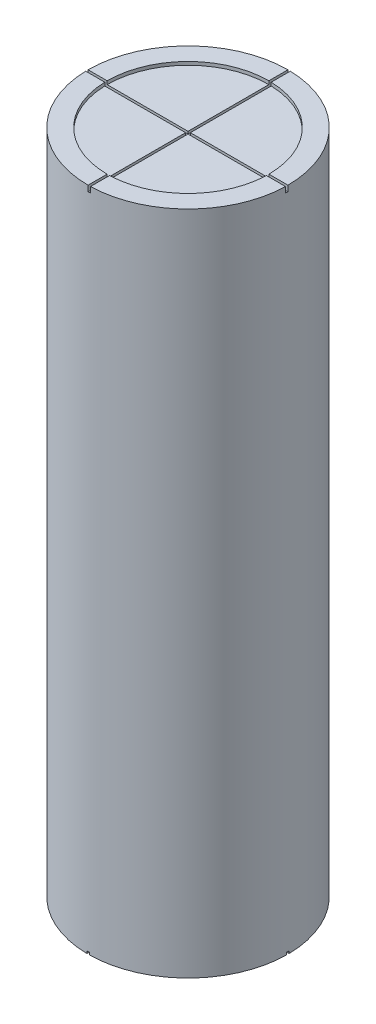
from build123d import *

# Parameters (mm, degrees)
SKETCH1_R               = 10.5
BOSS_EXTRUDE1_DEPTH     = 70
SKETCH2_R               = 8.5
CUT_EXTRUDE1_DEPTH      = 0.35
SKETCH3_W               = 21
SKETCH3_H               = 0.25
SKETCH3_W_2             = 0.25
SKETCH3_H_2             = 21
CUT_EXTRUDE_THIN1_DEPTH = 0.25
CUT_EXTRUDE_THIN2_START = 70
SKETCH3_2_W             = 21
SKETCH3_2_H             = 0.25
SKETCH3_2_W_2           = 0.25
SKETCH3_2_H_2           = 21
CUT_EXTRUDE_THIN2_DEPTH = 0.6


with BuildPart() as part:
    # Sketch1 → Boss-Extrude1 (new body)
    with BuildSketch(Plane(origin=(0, 0, 0), x_dir=(1, 0, 0), z_dir=(0, 1, 0))):
        Circle(SKETCH1_R)
    extrude(amount=BOSS_EXTRUDE1_DEPTH)

    # Sketch2 → Cut-Extrude1 (cut)
    with BuildSketch(Plane(origin=(0, 70, 0), x_dir=(1, 0, 0), z_dir=(0, 1, 0))):
        Circle(SKETCH2_R)
    extrude(amount=-CUT_EXTRUDE1_DEPTH, mode=Mode.SUBTRACT)

    # Sketch3 → Cut-Extrude-Thin1 (cut)
    with BuildSketch(Plane(origin=(0, 0, 0), x_dir=(1, 0, 0), z_dir=(0, 1, 0))):
        Rectangle(SKETCH3_W, SKETCH3_H)
        Rectangle(SKETCH3_W_2, SKETCH3_H_2)
    extrude(amount=CUT_EXTRUDE_THIN1_DEPTH, mode=Mode.SUBTRACT)

    # Sketch3_2 → Cut-Extrude-Thin2 (cut)
    with BuildSketch(Plane(origin=(0, 0, 0), x_dir=(1, 0, 0), z_dir=(0, 1, 0)).offset(CUT_EXTRUDE_THIN2_START)):
        with Locations((0, -0.125)):
            Rectangle(SKETCH3_2_W, SKETCH3_2_H)
        with Locations((0.125, 0)):
            Rectangle(SKETCH3_2_W_2, SKETCH3_2_H_2)
    extrude(amount=-CUT_EXTRUDE_THIN2_DEPTH, mode=Mode.SUBTRACT)


solid = part.part
